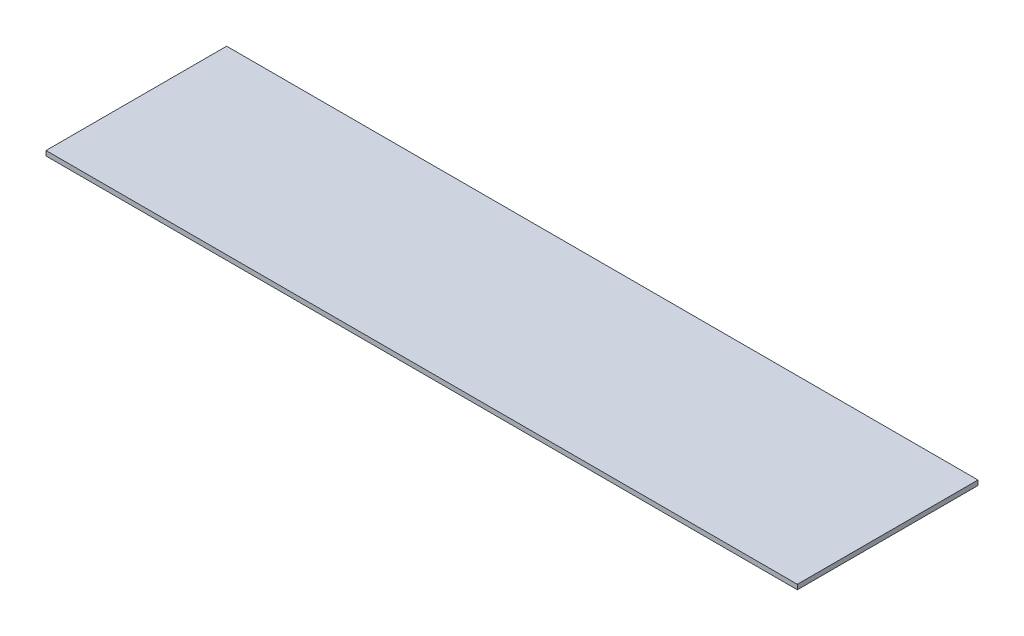
from build123d import *

# Parameters (mm, degrees)
SKETCH1_W      = 470
SKETCH1_H      = 113
EXTRUDE1_DEPTH = 3


with BuildPart() as part:
    # Sketch1 → Extrude1 (new body)
    with BuildSketch(Plane(origin=(0, 0, 0), x_dir=(1, 0, 0), z_dir=(0, 1, 0))):
        Rectangle(SKETCH1_W, SKETCH1_H)
    extrude(amount=EXTRUDE1_DEPTH)


solid = part.part
